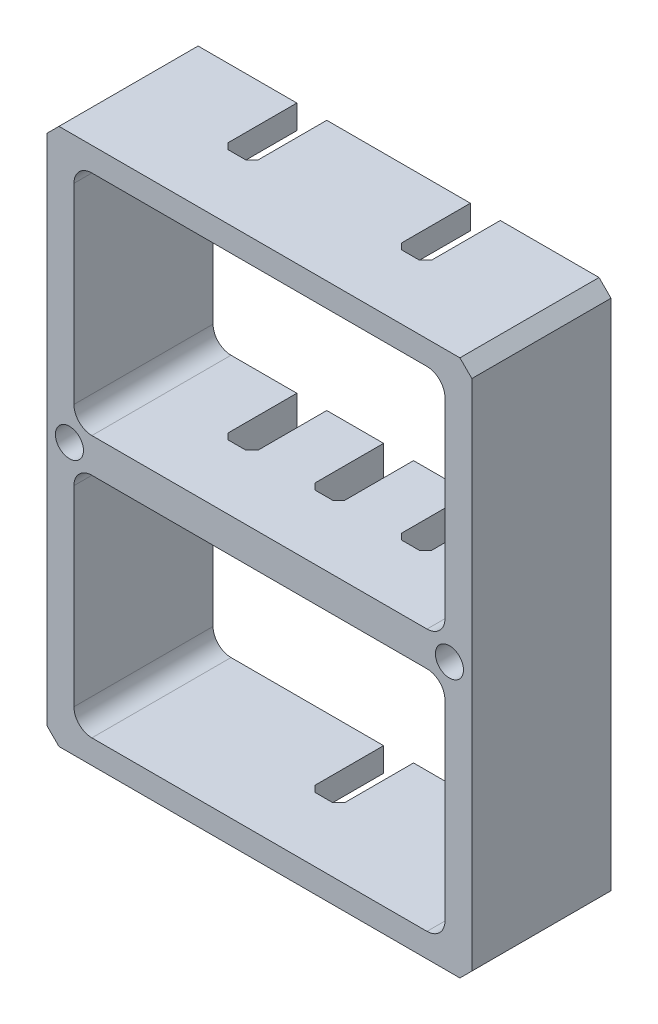
from build123d import *

# Parameters (mm, degrees)
SKETCH1_W               = 18.034
SKETCH1_H               = 22.7965
SKETCH1_W_2             = 15.748
SKETCH1_H_2             = 9.652
BOSS_EXTRUDE1_DEPTH     = 5.9055
SKETCH2_W               = 1.27
SKETCH2_H               = 1.016
SKETCH2_H_2             = 1.4605
CUT_EXTRUDE_THIN2_DEPTH = 3.175
CHAMFER1_SIZE           = 0.254
CHAMFER2_SIZE           = 0.508
FILLET1_R               = 0.762
F_0_80_TAPPED_HOLE1_D   = 1.19126


with BuildPart() as part:
    # Sketch1 → Boss-Extrude1 (new body)
    with BuildSketch(Plane.XY):
        with Locations((22.86, -68.54825)):
            Rectangle(SKETCH1_W, SKETCH1_H)
        with Locations((22.86, -62.992)):
            Rectangle(SKETCH1_W_2, SKETCH1_H_2, mode=Mode.SUBTRACT)
        with Locations((22.86, -74.1045)):
            Rectangle(SKETCH1_W_2, SKETCH1_H_2, mode=Mode.SUBTRACT)
    extrude(amount=BOSS_EXTRUDE1_DEPTH)

    # Sketch2 → Cut-Extrude-Thin2 (cut)
    with BuildSketch(Plane(origin=(0, 0, 0), x_dir=(-1, 0, 0), z_dir=(0, 0, -1))):
        with Locations((-22.86, -79.4385)):
            Rectangle(SKETCH2_W, SKETCH2_H)
        with Locations((-19.177, -57.658)):
            Rectangle(SKETCH2_W, SKETCH2_H)
        with Locations((-26.543, -57.658)):
            Rectangle(SKETCH2_W, SKETCH2_H)
        with Locations((-22.86, -68.54825)):
            Rectangle(SKETCH2_W, SKETCH2_H_2)
        with Locations((-19.177, -68.54825)):
            Rectangle(SKETCH2_W, SKETCH2_H_2)
        with Locations((-26.543, -68.54825)):
            Rectangle(SKETCH2_W, SKETCH2_H_2)
    extrude(amount=-CUT_EXTRUDE_THIN2_DEPTH, mode=Mode.SUBTRACT)

    # Chamfer1
    chamfer1_edges = [part.edges().sort_by_distance(p)[0] for p in [
        (22.225, -68.54825, 3.175),
        (23.495, -68.54825, 3.175),
        (25.908, -68.54825, 3.175),
        (27.178, -68.54825, 3.175),
        (23.495, -79.4385, 3.175),
        (22.225, -79.4385, 3.175),
        (19.812, -57.658, 3.175),
        (18.542, -57.658, 3.175),
        (27.178, -57.658, 3.175),
        (25.908, -57.658, 3.175),
        (18.542, -68.54825, 3.175),
        (19.812, -68.54825, 3.175),
    ]]
    chamfer(chamfer1_edges, length=CHAMFER1_SIZE)

    # Chamfer2
    chamfer2_edges = [part.edges().sort_by_distance(p)[0] for p in [
        (31.877, -57.15, 2.95275),
        (31.877, -79.9465, 2.95275),
        (13.843, -79.9465, 2.95275),
        (13.843, -57.15, 2.95275),
    ]]
    chamfer(chamfer2_edges, length=CHAMFER2_SIZE)

    # Fillet1
    fillet1_edges = [part.edges().sort_by_distance(p)[0] for p in [
        (30.734, -67.818, 2.95275),
        (30.734, -58.166, 2.95275),
        (14.986, -78.9305, 2.95275),
        (30.734, -78.9305, 2.95275),
        (14.986, -58.166, 2.95275),
        (14.986, -67.818, 2.95275),
        (30.734, -69.2785, 2.95275),
        (14.986, -69.2785, 2.95275),
    ]]
    fillet(fillet1_edges, radius=FILLET1_R)

    # #0-80 Tapped Hole1 (through all)
    with Locations(Plane(origin=(0, 0, 0), x_dir=(-1, 0, 0), z_dir=(0, 0, -1))):
        with Locations((-30.9245, -68.54825), (-14.7955, -68.54825)):
            Hole(F_0_80_TAPPED_HOLE1_D / 2)


solid = part.part
